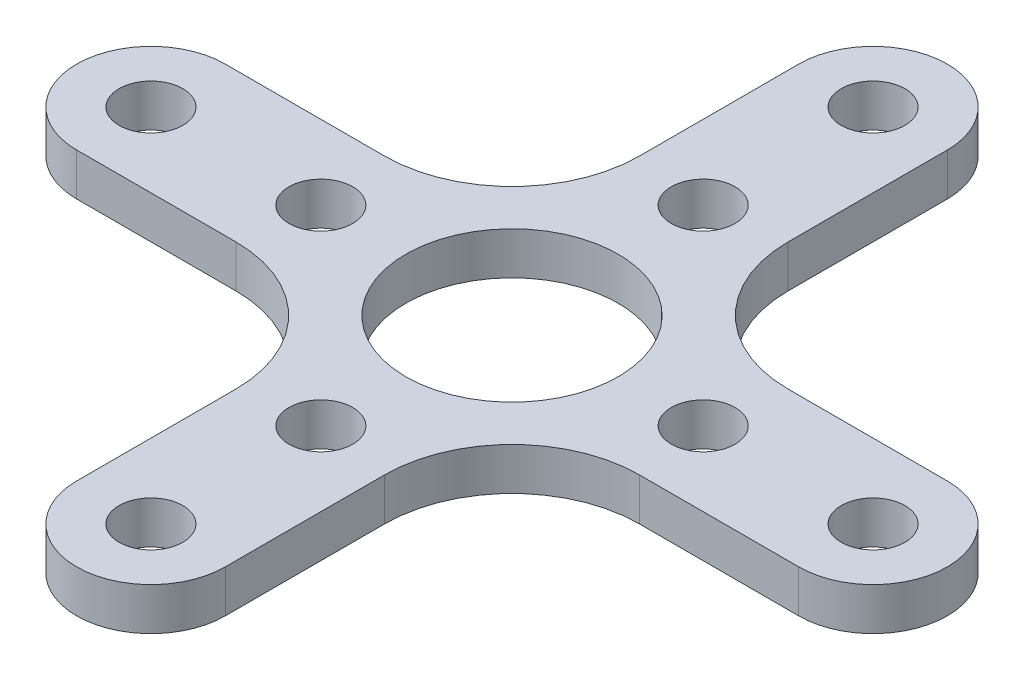
from build123d import *

# Parameters (mm, degrees)
BOSS_EXTRUDE1_DEPTH = 2
SKETCH2_R           = 1.5
SKETCH2_R_2         = 5
CUT_EXTRUDE1_DEPTH  = 2


with BuildPart() as part:
    # Sketch1 → Boss-Extrude1 (new body)
    with BuildSketch(Plane(origin=(0, 0, 0), x_dir=(1, 0, 0), z_dir=(0, 1, 0))):
        with BuildLine():
            Line((-3.5, 17), (-3.5, 9.5))
            ThreePointArc((-3.5, 9.5), (-5.257359313, 5.257359313), (-9.5, 3.5))
            Line((-9.5, 3.5), (-17, 3.5))
            ThreePointArc((-17, 3.5), (-20.5, 0), (-17, -3.5))
            Line((-17, -3.5), (-9.5, -3.5))
            ThreePointArc((-9.5, -3.5), (-5.257359313, -5.257359313), (-3.5, -9.5))
            Line((-3.5, -9.5), (-3.5, -17))
            ThreePointArc((-3.5, -17), (0, -20.5), (3.5, -17))
            Line((3.5, -17), (3.5, -9.5))
            ThreePointArc((3.5, -9.5), (5.257359313, -5.257359313), (9.5, -3.5))
            Line((9.5, -3.5), (17, -3.5))
            ThreePointArc((17, -3.5), (20.5, 0), (17, 3.5))
            Line((17, 3.5), (9.5, 3.5))
            ThreePointArc((9.5, 3.5), (5.257359313, 5.257359313), (3.5, 9.5))
            Line((3.5, 9.5), (3.5, 17))
            ThreePointArc((3.5, 17), (0, 20.5), (-3.5, 17))
        make_face()
    extrude(amount=BOSS_EXTRUDE1_DEPTH)

    # Sketch2 → Cut-Extrude1 (cut)
    with BuildSketch(Plane(origin=(0, 2, 0), x_dir=(1, 0, 0), z_dir=(0, 1, 0))):
        with Locations((0, 17)):
            Circle(SKETCH2_R)
        with Locations((0, 9)):
            Circle(SKETCH2_R)
        Circle(SKETCH2_R_2)
        with Locations((17, 0)):
            Circle(SKETCH2_R)
        with Locations((9, 0)):
            Circle(SKETCH2_R)
        with Locations((0, -17)):
            Circle(SKETCH2_R)
        with Locations((0, -9)):
            Circle(SKETCH2_R)
        with Locations((-17, 0)):
            Circle(SKETCH2_R)
        with Locations((-9, 0)):
            Circle(SKETCH2_R)
    extrude(amount=-CUT_EXTRUDE1_DEPTH, mode=Mode.SUBTRACT)


solid = part.part
